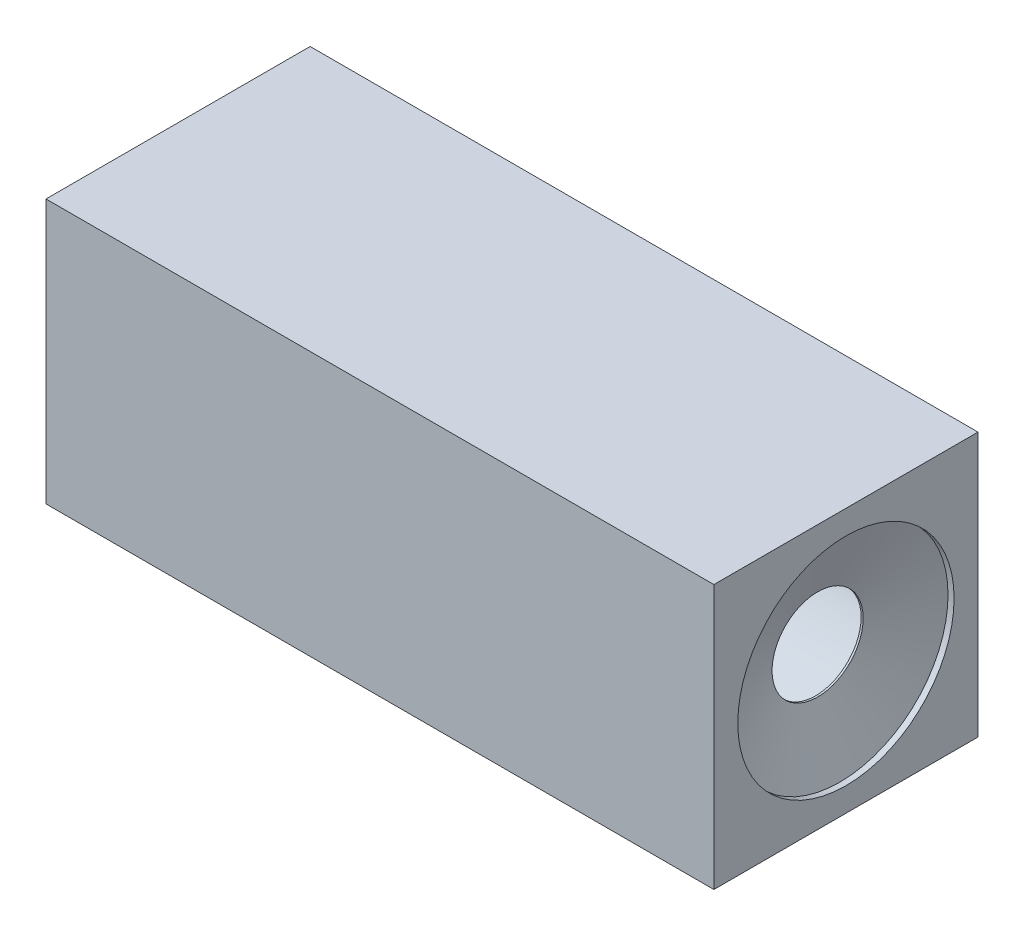
from build123d import *

# Parameters (mm, degrees)
SKETCH_1_W          = 130.5
SKETCH_1_H          = 130.5
EXTRUDE_1_DEPTH     = 330
SKETCH_8_R          = 56.25
CUT_EXTRUDE_2_DEPTH = 315


with BuildPart() as part:
    # 草图1 → 凸台-拉伸1 (new body)
    with BuildSketch(Plane(origin=(0, 0, 0), x_dir=(0, 0, -1), z_dir=(1, 0, 0))):
        Rectangle(SKETCH_1_W, SKETCH_1_H)
    extrude(amount=EXTRUDE_1_DEPTH)

    # 草图8 → 切除-拉伸2 (cut)
    with BuildSketch(Plane.ZY):
        Circle(SKETCH_8_R)
    extrude(amount=-CUT_EXTRUDE_2_DEPTH, mode=Mode.SUBTRACT)

    # 草图26 → 切除-旋转3 (revolve, cut)
    with BuildSketch(Plane(origin=(0, 0, 0), x_dir=(-1, 0, 0), z_dir=(0, 0, -1))):
        Polygon((-315, 0), (-315, 22.5), (-316, 22.5), (-327, 53.439293368), (-330, 53.439293368), (-330, 0), align=None)
    revolve(axis=Axis((315, 0, 0), (-1, 0, 0)), mode=Mode.SUBTRACT)


solid = part.part
